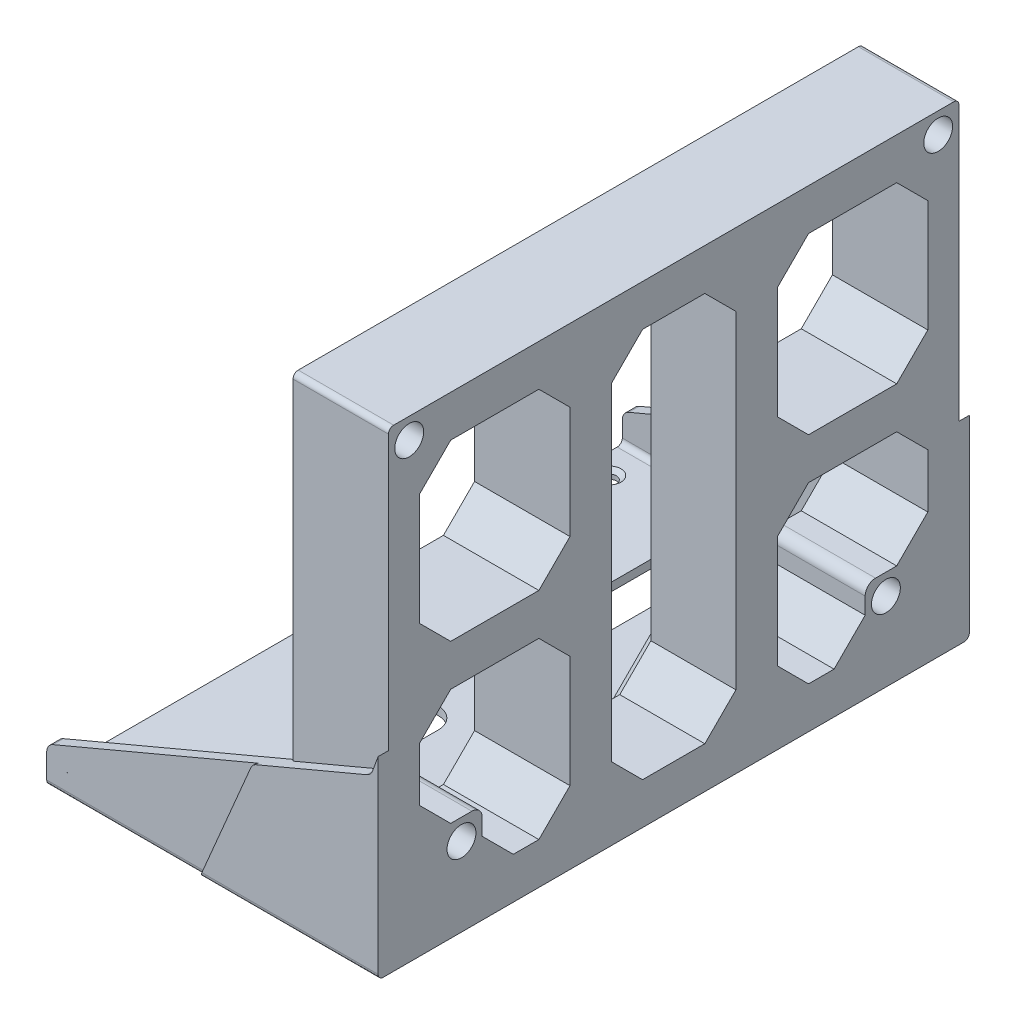
from build123d import *

# Parameters (mm, degrees)
SKETCH2_W                                 = 180.975
SKETCH2_H                                 = 144.78
BOSS_EXTRUDE1_DEPTH                       = 149.225
BOSS_EXTRUDE2_DEPTH                       = 3.175
BOSS_EXTRUDE3_DEPTH                       = 3.175
BOSS_EXTRUDE4_DEPTH                       = 3.175
CUT_EXTRUDE1_DEPTH                        = 3.175
SKETCH7_W                                 = 73.025
SKETCH7_H                                 = 171.45
BOSS_EXTRUDE6_DEPTH                       = 2.54
FILLET1_R                                 = 1.5875
SKETCH10_W                                = 155.575
SKETCH10_H                                = 119.38
CUT_EXTRUDE2_DEPTH                        = 223.25
FILLET3_R                                 = 3.175
CHAMFER1_SIZE                             = 6.35
FILLET4_R                                 = 6.35
SKETCH11_W                                = 180.975
SKETCH11_H                                = 144.78
CUT_EXTRUDE3_DEPTH                        = 82.55
CUT_EXTRUDE4_REACH                        = 146.78
BOSS_EXTRUDE7_DEPTH                       = 66.675
BOSS_EXTRUDE8_DEPTH                       = 9.525
S_0_348_DIAMETER_HOLE1_D                  = 8.8392
CSK_FOR_6_FLAT_HEAD_MACHINE_SCREW_2_COUNT = 2
CSK_FOR_6_FLAT_HEAD_MACHINE_SCREW_2_PITCH = 46.0375
CSK_FOR_6_FLAT_HEAD_MACHINE_SCREW_3_COUNT = 2
CSK_FOR_6_FLAT_HEAD_MACHINE_SCREW_3_PITCH = 159.201794608
CSK_FOR_6_FLAT_HEAD_MACHINE_SCREW_4_COUNT = 2
CSK_FOR_6_FLAT_HEAD_MACHINE_SCREW_4_PITCH = 152.4
CSK_FOR_6_FLAT_HEAD_MACHINE_SCREW_5_COUNT = 2
CSK_FOR_6_FLAT_HEAD_MACHINE_SCREW_5_PITCH = 79.600897304
F_1_4_CLEARANCE_HOLE1_D                   = 7.14248
SKETCH22_W                                = 180.975
SKETCH22_H                                = 144.78
RELIEF_FOR_MIP_FACE_SUPPORT_DEPTH         = 37.465
SKETCH23_W                                = 6.35
SKETCH23_H                                = 119.38
SKETCH23_W_2                              = 155.575
SKETCH23_H_2                              = 6.35
EXTRUDE_THIN1_DEPTH                       = 29.21
FILLET6_R                                 = 6.35
CUT_EXTRUDE5_DEPTH                        = 29.21
SKETCH25_W                                = 12.7
SKETCH25_H                                = 119.38
SKETCH25_W_2                              = 52.3875
SKETCH25_H_2                              = 12.7
EXTRUDE_THIN2_DEPTH                       = 29.21
CHAMFER2_SIZE                             = 9.525
CHAMFER3_SIZE                             = 3.175
BOSS_EXTRUDE9_DEPTH                       = 2.38125
CUT_EXTRUDE6_DEPTH                        = 2.38125
FILLET7_R                                 = 1.5875
FILLET8_R                                 = 1.5875


with BuildPart() as part:
    # Sketch2 → Boss-Extrude1 (new body)
    with BuildSketch(Plane(origin=(149.225, 0, 0), x_dir=(0, 0, -1), z_dir=(1, 0, 0))):
        with Locations((84.0105, -72.39)):
            Rectangle(SKETCH2_W, SKETCH2_H)
    extrude(amount=-BOSS_EXTRUDE1_DEPTH)

    # Sketch3_3 → Boss-Extrude2 (add)
    with BuildSketch(Plane.XY.offset(6.477)):
        Polygon((-9.271174074, -106.782867284), (-25.4, -144.78), (149.225, -144.78), (149.225, 0), (60.325, 0), (27.03103123, -91.474427399), align=None)
    extrude(amount=-BOSS_EXTRUDE2_DEPTH)



with BuildPart() as body_2:
    # Sketch4 → Boss-Extrude3 (new body)
    with BuildSketch(Plane.XY.offset(0.127)):
        Polygon((-73.025, -133.667504276), (-73.025, -144.78), (-25.4, -144.78), (-9.271174074, -106.782867284), align=None)
    extrude(amount=BOSS_EXTRUDE3_DEPTH)


with BuildPart() as part_1:
    add(part.part)

    add(body_2.part)  # Boss-Extrude4 merges body 2
    # Sketch5 → Boss-Extrude4 (add)
    with BuildSketch(Plane(origin=(0, 0, 3.302), x_dir=(-1, 0, 0), z_dir=(0, 0, -1))):
        Polygon((0, -102.873264278), (0, -144.78), (25.4, -144.78), (9.271174074, -106.782867284), align=None)
    extrude(amount=BOSS_EXTRUDE4_DEPTH)

    # Mirror5: part across plane


with BuildPart() as part_2:
    add(part_1.part)
    add(part_1.part.mirror(Plane.XY.offset(-84.0105)))

    # Sketch3 → Cut-Extrude1 (cut)
    with BuildSketch(Plane.XY.offset(6.477)):
        Polygon((27.03103123, -91.474427399), (60.325, 0), (0, 0), (0, -102.873264278), align=None)
    cut_extrude1 = extrude(amount=-CUT_EXTRUDE1_DEPTH, mode=Mode.SUBTRACT)

    # Mirror6: Cut-Extrude1 across plane
    add(cut_extrude1.mirror(Plane.XY.offset(-84.0105)), mode=Mode.SUBTRACT)

    # Sketch7 → Boss-Extrude6 (add)
    with BuildSketch(Plane.XZ.offset(144.78)):
        with Locations((-36.5125, -85.598)):
            Rectangle(SKETCH7_W, SKETCH7_H)
    extrude(amount=-BOSS_EXTRUDE6_DEPTH)

    # Fillet1
    fillet1_edges = [part_2.edges().sort_by_distance(p)[0] for p in [
        (30.1625, 0, 3.302),
        (30.1625, 0, -171.323),
    ]]
    fillet(fillet1_edges, radius=FILLET1_R)

    # Sketch10 → Cut-Extrude2 (cut, through all)
    with BuildSketch(Plane(origin=(149.225, 0, 0), x_dir=(0, 0, -1), z_dir=(1, 0, 0))):
        with Locations((84.0105, -72.39)):
            Rectangle(SKETCH10_W, SKETCH10_H)
    extrude(amount=-CUT_EXTRUDE2_DEPTH, mode=Mode.SUBTRACT)

    # Fillet3
    fillet3_edges = [part_2.edges().sort_by_distance(p)[0] for p in [
        (27.03103123, -91.474427399, 4.8895),
        (27.03103123, -91.474427399, -172.9105),
        (-9.271174074, -106.782867284, 4.8895),
        (-73.025, -133.667504276, 1.7145),
        (-73.025, -133.667504276, -169.7355),
        (-9.271174074, -106.782867284, -172.9105),
    ]]
    fillet(fillet3_edges, radius=FILLET3_R)

    # Chamfer1
    chamfer1_edges = [part_2.edges().sort_by_distance(p)[0] for p in [
        (74.6125, -12.7, -161.798),
        (74.6125, -132.08, -161.798),
        (74.6125, -132.08, -6.223),
        (74.6125, -12.7, -6.223),
    ]]
    chamfer(chamfer1_edges, length=CHAMFER1_SIZE)

    # Fillet4
    fillet4_edges = [part_2.edges().sort_by_distance(p)[0] for p in [
        (74.6125, -125.73, -6.223),
        (74.6125, -19.05, -6.223),
        (74.6125, -12.7, -155.448),
        (74.6125, -12.7, -12.573),
        (74.6125, -132.08, -155.448),
        (74.6125, -132.08, -12.573),
        (74.6125, -19.05, -161.798),
        (74.6125, -125.73, -161.798),
    ]]
    fillet(fillet4_edges, radius=FILLET4_R)

    # Sketch11 → Cut-Extrude3 (cut)
    with BuildSketch(Plane(origin=(149.225, 0, 0), x_dir=(0, 0, -1), z_dir=(1, 0, 0))):
        with Locations((84.0105, -72.39)):
            Rectangle(SKETCH11_W, SKETCH11_H)
    extrude(amount=-CUT_EXTRUDE3_DEPTH, mode=Mode.SUBTRACT)

    # Sketch12 → Cut-Extrude4 (cut, up to next)
    with BuildSketch(Plane.XZ.offset(144.78), mode=Mode.PRIVATE) as cut_extrude4_sk1:
        with BuildLine():
            Line((-38.1, -101.473), (-38.1, -152.273))
            ThreePointArc((-38.1, -152.273), (-31.75, -158.623), (-25.4, -152.273))
            Line((-25.4, -152.273), (-25.4, -101.473))
            ThreePointArc((-25.4, -101.473), (-31.75, -95.123), (-38.1, -101.473))
        make_face()
    cut_extrude4_tool1 = extrude(cut_extrude4_sk1.sketch, amount=-CUT_EXTRUDE4_REACH, mode=Mode.PRIVATE) & part_2.part
    add(cut_extrude4_tool1.solids().sort_by_distance((-31.75, -144.78, -126.873))[0], mode=Mode.SUBTRACT)
    # Sketch12 → Cut-Extrude4 (cut, up to next)
    with BuildSketch(Plane.XZ.offset(144.78), mode=Mode.PRIVATE) as cut_extrude4_sk2:
        with BuildLine():
            Line((-25.4, -66.548), (-25.4, -15.748))
            ThreePointArc((-25.4, -15.748), (-31.75, -9.398), (-38.1, -15.748))
            Line((-38.1, -15.748), (-38.1, -66.548))
            ThreePointArc((-38.1, -66.548), (-31.75, -72.898), (-25.4, -66.548))
        make_face()
    cut_extrude4_tool2 = extrude(cut_extrude4_sk2.sketch, amount=-CUT_EXTRUDE4_REACH, mode=Mode.PRIVATE) & part_2.part
    add(cut_extrude4_tool2.solids().sort_by_distance((-31.75, -144.78, -41.148))[0], mode=Mode.SUBTRACT)

    # Sketch18 → Boss-Extrude7 (add)
    with BuildSketch(Plane(origin=(66.675, 0, 0), x_dir=(0, 0, -1), z_dir=(1, 0, 0))):
        with BuildLine():
            Line((15.203256121, -132.08), (25.4, -132.08))
            Line((25.4, -132.08), (25.4, -117.475))
            ThreePointArc((25.4, -117.475), (24.47006403, -115.22993597), (22.225, -114.3))
            Line((22.225, -114.3), (6.223, -114.3))
            Line((6.223, -114.3), (6.223, -123.099743879))
            ThreePointArc((6.223, -123.099743879), (6.706364969, -125.529783674), (8.082871939, -127.589871939))
            Line((8.082871939, -127.589871939), (10.713128061, -130.220128061))
            ThreePointArc((10.713128061, -130.220128061), (12.773216326, -131.596635031), (15.203256121, -132.08))
        make_face()
        with BuildLine():
            Line((161.798, -123.099743879), (161.798, -114.3))
            Line((161.798, -114.3), (145.796, -114.3))
            ThreePointArc((145.796, -114.3), (143.55093597, -115.22993597), (142.621, -117.475))
            Line((142.621, -117.475), (142.621, -132.08))
            Line((142.621, -132.08), (152.817743879, -132.08))
            ThreePointArc((152.817743879, -132.08), (155.247783674, -131.596635031), (157.307871939, -130.220128061))
            Line((157.307871939, -130.220128061), (159.938128061, -127.589871939))
            ThreePointArc((159.938128061, -127.589871939), (161.314635031, -125.529783674), (161.798, -123.099743879))
        make_face()
    extrude(amount=-BOSS_EXTRUDE7_DEPTH)

    # Sketch18_3 → Boss-Extrude8 (add)
    with BuildSketch(Plane(origin=(66.675, 0, 0), x_dir=(0, 0, -1), z_dir=(1, 0, 0))):
        with BuildLine():
            Line((145.796, -30.48), (161.798, -30.48))
            Line((161.798, -30.48), (161.798, -21.680256121))
            ThreePointArc((161.798, -21.680256121), (161.314635031, -19.250216326), (159.938128061, -17.190128061))
            Line((159.938128061, -17.190128061), (157.307871939, -14.559871939))
            ThreePointArc((157.307871939, -14.559871939), (155.247783674, -13.183364969), (152.817743879, -12.7))
            Line((152.817743879, -12.7), (142.621, -12.7))
            Line((142.621, -12.7), (142.621, -27.305))
            ThreePointArc((142.621, -27.305), (143.55093597, -29.55006403), (145.796, -30.48))
        make_face()
        with BuildLine():
            Line((25.4, -27.305), (25.4, -12.7))
            Line((25.4, -12.7), (15.203256121, -12.7))
            ThreePointArc((15.203256121, -12.7), (12.773216326, -13.183364969), (10.713128061, -14.559871939))
            Line((10.713128061, -14.559871939), (8.082871939, -17.190128061))
            ThreePointArc((8.082871939, -17.190128061), (6.706364969, -19.250216326), (6.223, -21.680256121))
            Line((6.223, -21.680256121), (6.223, -30.48))
            Line((6.223, -30.48), (22.225, -30.48))
            ThreePointArc((22.225, -30.48), (24.47006403, -29.55006403), (25.4, -27.305))
        make_face()
    extrude(amount=-BOSS_EXTRUDE8_DEPTH)

    # S _0.348_ Diameter Hole1 (through all)
    with Locations(Plane.ZY):
        with Locations((-164.973, -6.35), (-3.048, -6.35), (-19.05, -120.65), (-148.971, -120.65)):
            Hole(S_0_348_DIAMETER_HOLE1_D / 2)

    # Sketch17 → CSK for _6 Flat Head Machine Screw _100 (revolve, cut)
    with BuildSketch(Plane(origin=(-20.6375, -142.24, -7.8105), x_dir=(0, 0, 1), z_dir=(1, 0, 0))):
        Polygon((0, 0), (0, 2.54), (2.15265, 2.54), (2.15265, 1.166893902), (3.5433, 0), align=None)
    csk_for_6_flat_head_machine_screw_100 = revolve(axis=Axis((-20.6375, -135.89, -7.8105), (0, -1, 0)), mode=Mode.SUBTRACT)

    # CSK for _6 Flat Head Machine Screw _ 2: CSK for _6 Flat Head Machine Screw _100 ×2
    with Locations(*[(-i * CSK_FOR_6_FLAT_HEAD_MACHINE_SCREW_2_PITCH, 0, 0) for i in range(1, CSK_FOR_6_FLAT_HEAD_MACHINE_SCREW_2_COUNT)]):
        add(csk_for_6_flat_head_machine_screw_100, mode=Mode.SUBTRACT)

    # CSK for _6 Flat Head Machine Screw _ 3: CSK for _6 Flat Head Machine Screw _100 ×2
    with Locations(*[Vector(-0.289177017, 0, -0.957275641) * (i * CSK_FOR_6_FLAT_HEAD_MACHINE_SCREW_3_PITCH) for i in range(1, CSK_FOR_6_FLAT_HEAD_MACHINE_SCREW_3_COUNT)]):
        add(csk_for_6_flat_head_machine_screw_100, mode=Mode.SUBTRACT)

    # CSK for _6 Flat Head Machine Screw _ 4: CSK for _6 Flat Head Machine Screw _100 ×2
    with Locations(*[(0, 0, -i * CSK_FOR_6_FLAT_HEAD_MACHINE_SCREW_4_PITCH) for i in range(1, CSK_FOR_6_FLAT_HEAD_MACHINE_SCREW_4_COUNT)]):
        add(csk_for_6_flat_head_machine_screw_100, mode=Mode.SUBTRACT)

    # CSK for _6 Flat Head Machine Screw _ 5: CSK for _6 Flat Head Machine Screw _100 ×2
    with Locations(*[Vector(-0.289177017, 0, -0.957275641) * (i * CSK_FOR_6_FLAT_HEAD_MACHINE_SCREW_5_PITCH) for i in range(1, CSK_FOR_6_FLAT_HEAD_MACHINE_SCREW_5_COUNT)]):
        add(csk_for_6_flat_head_machine_screw_100, mode=Mode.SUBTRACT)

    # 1_4 Clearance Hole1 (through all)
    with Locations(Plane.ZY.offset(-57.15)):
        with Locations((-19.05, -24.13), (-148.971, -24.13)):
            Hole(F_1_4_CLEARANCE_HOLE1_D / 2)

    # Sketch22 → Relief for MIP face support (cut)
    with BuildSketch(Plane(origin=(66.675, 0, 0), x_dir=(0, 0, -1), z_dir=(1, 0, 0))):
        with Locations((84.0105, -72.39)):
            Rectangle(SKETCH22_W, SKETCH22_H)
    extrude(amount=-RELIEF_FOR_MIP_FACE_SUPPORT_DEPTH, mode=Mode.SUBTRACT)

    # Sketch23 → Extrude-Thin1 (add)
    with BuildSketch(Plane(origin=(29.21, 0, 0), x_dir=(0, 0, -1), z_dir=(1, 0, 0))):
        with Locations((84.0105, -72.39)):
            Rectangle(SKETCH23_W, SKETCH23_H)
        with Locations((84.0105, -67.990128061)):
            Rectangle(SKETCH23_W_2, SKETCH23_H_2)
    extrude(amount=-EXTRUDE_THIN1_DEPTH)

    # Fillet6
    fillet6_edges = [part_2.edges().sort_by_distance(p)[0] for p in [
        (14.605, -132.08, -80.8355),
        (14.605, -71.165128061, -87.1855),
        (14.605, -12.7, -80.8355),
        (14.605, -64.815128061, -80.8355),
        (14.605, -132.08, -87.1855),
        (14.605, -12.7, -87.1855),
        (14.605, -64.815128061, -161.798),
        (14.605, -64.815128061, -87.1855),
        (14.605, -71.165128061, -161.798),
        (14.605, -71.165128061, -80.8355),
        (14.605, -64.815128061, -6.223),
        (14.605, -71.165128061, -6.223),
    ]]
    fillet(fillet6_edges, radius=FILLET6_R)

    # Sketch24 → Cut-Extrude5 (cut)
    with BuildSketch(Plane(origin=(29.21, 0, 0), x_dir=(0, 0, -1), z_dir=(1, 0, 0))):
        Polygon((25.4, -132.08), (25.4, -114.3), (6.223, -114.3), (6.223, -12.7), (161.798, -12.7), (161.798, -114.3), (142.621, -114.3), (142.621, -132.08), align=None)
    extrude(amount=-CUT_EXTRUDE5_DEPTH, mode=Mode.SUBTRACT)

    # Sketch25 → Extrude-Thin2 (add)
    with BuildSketch(Plane(origin=(29.21, 0, 0), x_dir=(0, 0, -1), z_dir=(1, 0, 0))):
        with Locations((58.6105, -72.39)):
            Rectangle(SKETCH25_W, SKETCH25_H)
        with Locations((32.41675, -72.39)):
            Rectangle(SKETCH25_W_2, SKETCH25_H_2)
        with Locations((135.60425, -72.39)):
            Rectangle(SKETCH25_W_2, SKETCH25_H_2)
        with Locations((109.4105, -72.39)):
            Rectangle(SKETCH25_W, SKETCH25_H)
    extrude(amount=-EXTRUDE_THIN2_DEPTH)

    # Chamfer2
    chamfer2_edges = [part_2.edges().sort_by_distance(p)[0] for p in [
        (14.605, -114.3, -6.223),
        (14.605, -132.08, -25.4),
        (14.605, -114.3, -161.798),
        (14.605, -132.08, -142.621),
        (14.605, -12.7, -6.223),
        (14.605, -12.7, -161.798),
        (14.605, -132.08, -52.2605),
        (14.605, -12.7, -52.2605),
        (14.605, -66.04, -52.2605),
        (14.605, -132.08, -64.9605),
        (14.605, -12.7, -64.9605),
        (14.605, -78.74, -52.2605),
        (14.605, -66.04, -6.223),
        (14.605, -78.74, -6.223),
        (14.605, -66.04, -161.798),
        (14.605, -66.04, -115.7605),
        (14.605, -78.74, -161.798),
        (14.605, -12.7, -115.7605),
        (14.605, -12.7, -103.0605),
        (14.605, -132.08, -103.0605),
        (14.605, -132.08, -115.7605),
        (14.605, -78.74, -115.7605),
    ]]
    chamfer(chamfer2_edges, length=CHAMFER2_SIZE)

    # Chamfer3
    chamfer3_edges = [part_2.edges().sort_by_distance(p)[0] for p in [
        (0, -12.7, -84.0105),
        (0, -72.39, -103.0605),
        (0, -72.39, -64.9605),
        (0, -132.08, -84.0105),
        (0, -17.4625, -98.298),
        (0, -17.4625, -69.723),
        (0, -127.3175, -69.723),
        (0, -127.3175, -98.298),
    ]]
    chamfer(chamfer3_edges, length=CHAMFER3_SIZE)

    # Sketch26 → Boss-Extrude9 (add)
    with BuildSketch(Plane.XY.offset(3.302)):
        with BuildLine():
            Line((-8.085172656, -106.282737023), (-71.083675787, -132.848858556))
            ThreePointArc((-71.083675787, -132.848858556), (-72.495519384, -134.018858371), (-73.025, -135.77437886))
            Line((-73.025, -135.77437886), (-73.025, -144.78))
            Line((-73.025, -144.78), (-25.4, -144.78))
            Line((-25.4, -144.78), (-9.774099778, -107.967685994))
            ThreePointArc((-9.774099778, -107.967685994), (-9.093912176, -106.960547695), (-8.085172656, -106.282737023))
        make_face()
    boss_extrude9 = extrude(amount=BOSS_EXTRUDE9_DEPTH)

    # Sketch28 → Cut-Extrude6 (cut)
    with BuildSketch(Plane(origin=(0, 0, 0.127), x_dir=(-1, 0, 0), z_dir=(0, 0, -1))):
        with BuildLine():
            Line((73.025, -142.24), (73.025, -135.77437886))
            ThreePointArc((73.025, -135.77437886), (72.495519384, -134.018858371), (71.083675787, -132.848858556))
            Line((71.083675787, -132.848858556), (0, -102.873264278))
            Line((0, -102.873264278), (0, -142.24))
            Line((0, -142.24), (73.025, -142.24))
        make_face()
    cut_extrude6 = extrude(amount=-CUT_EXTRUDE6_DEPTH, mode=Mode.SUBTRACT)

    # Mirror10: Boss-Extrude9, Cut-Extrude6 across plane
    add(boss_extrude9.mirror(Plane.XY.offset(-84.0105)))
    add(cut_extrude6.mirror(Plane.XY.offset(-84.0105)), mode=Mode.SUBTRACT)

    # Fillet7
    fillet7_edges = [part_2.edges().sort_by_distance(p)[0] for p in [
        (-49.2125, -144.78, 5.68325),
        (-36.5125, -142.24, 2.50825),
        (-49.2125, -144.78, -173.70425),
        (-36.5125, -142.24, -170.52925),
    ]]
    fillet(fillet7_edges, radius=FILLET7_R)

    # Fillet8
    fillet8_edges = [part_2.edges().sort_by_distance(p)[0] for p in [
        (1.905, -144.78, 6.477),
        (1.905, -144.78, -174.498),
    ]]
    fillet(fillet8_edges, radius=FILLET8_R)


solid = part_2.part
